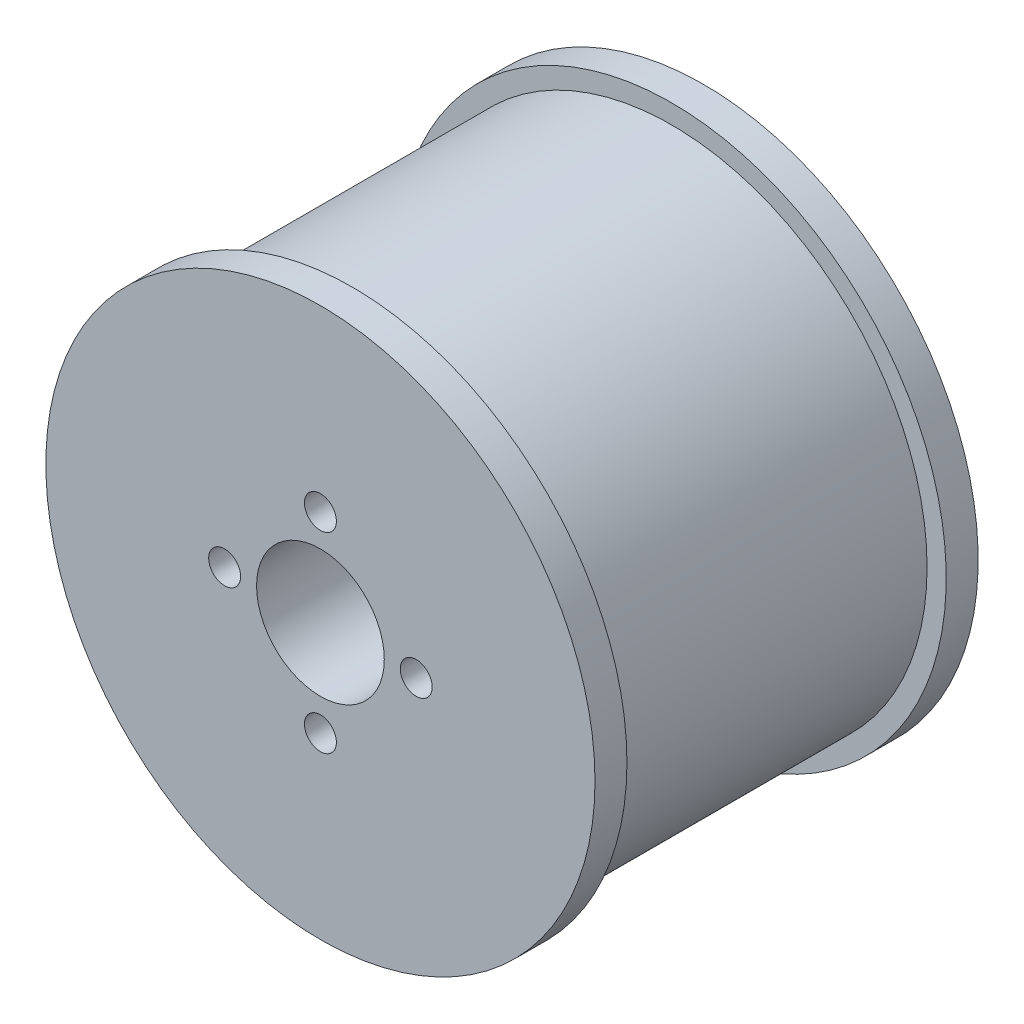
from build123d import *

# Parameters (mm, degrees)
SKETCH1_R           = 40
SKETCH1_R_2         = 10
BOSS_EXTRUDE1_DEPTH = 50
SKETCH2_R           = 43
SKETCH2_R_2         = 10
BOSS_EXTRUDE2_DEPTH = 5
SKETCH3_R           = 43
SKETCH3_R_2         = 10
BOSS_EXTRUDE3_DEPTH = 5
SKETCH4_R           = 2.5
CUT_EXTRUDE1_DEPTH  = 61


with BuildPart() as part:
    # Sketch1 → Boss-Extrude1 (new body)
    with BuildSketch(Plane.XY):
        Circle(SKETCH1_R)
        Circle(SKETCH1_R_2, mode=Mode.SUBTRACT)
    extrude(amount=BOSS_EXTRUDE1_DEPTH)

    # Sketch2 → Boss-Extrude2 (add)
    with BuildSketch(Plane.XY.offset(50)):
        Circle(SKETCH2_R)
        Circle(SKETCH2_R_2, mode=Mode.SUBTRACT)
    extrude(amount=BOSS_EXTRUDE2_DEPTH)

    # Sketch3 → Boss-Extrude3 (add)
    with BuildSketch(Plane(origin=(0, 0, 0), x_dir=(-1, 0, 0), z_dir=(0, 0, -1))):
        Circle(SKETCH3_R)
        Circle(SKETCH3_R_2, mode=Mode.SUBTRACT)
    extrude(amount=BOSS_EXTRUDE3_DEPTH)

    # Sketch4 → Cut-Extrude1 (cut, through all)
    with BuildSketch(Plane.XY.offset(55)):
        with Locations((0, 15)):
            Circle(SKETCH4_R)
        with Locations((15, 0)):
            Circle(SKETCH4_R)
        with Locations((0, -15)):
            Circle(SKETCH4_R)
        with Locations((-15, 0)):
            Circle(SKETCH4_R)
    extrude(amount=-CUT_EXTRUDE1_DEPTH, mode=Mode.SUBTRACT)


solid = part.part
